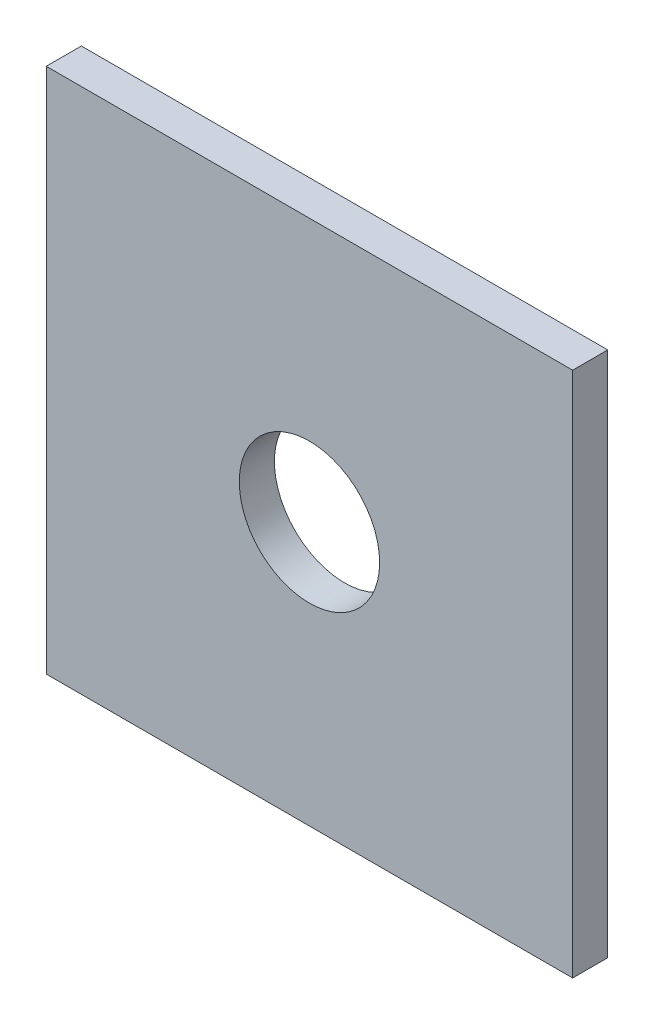
from build123d import *

# Parameters (mm, degrees)
SKETCH1_W           = 23.8125
SKETCH1_H           = 23.8125
SKETCH1_R           = 3.175
BOSS_EXTRUDE1_DEPTH = 1.5875


with BuildPart() as part:
    # Sketch1 → Boss-Extrude1 (new body)
    with BuildSketch(Plane.XY):
        Rectangle(SKETCH1_W, SKETCH1_H)
        Circle(SKETCH1_R, mode=Mode.SUBTRACT)
    extrude(amount=BOSS_EXTRUDE1_DEPTH)


solid = part.part
